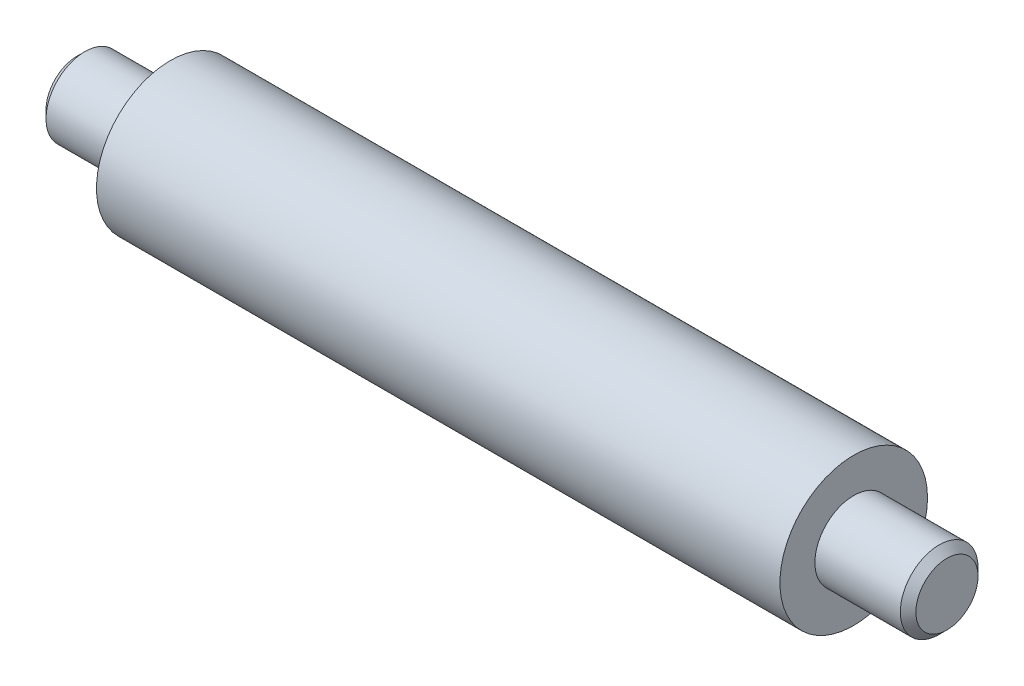
from build123d import *

# Parameters (mm, degrees)
SKETCH1_R           = 47.5
BOSS_EXTRUDE1_DEPTH = 220
SKETCH2_R           = 25
BOSS_EXTRUDE2_DEPTH = 280
CHAMFER1_SIZE       = 5


with BuildPart() as part:
    # Sketch1 → Boss-Extrude1 (new body, symmetric)
    with BuildSketch(Plane(origin=(0, 0, 0), x_dir=(0, 0, -1), z_dir=(1, 0, 0))):
        Circle(SKETCH1_R)
    extrude(amount=BOSS_EXTRUDE1_DEPTH, both=True)

    # Sketch2 → Boss-Extrude2 (add, symmetric)
    with BuildSketch(Plane(origin=(0, 0, 0), x_dir=(0, 0, -1), z_dir=(1, 0, 0))):
        Circle(SKETCH2_R)
    extrude(amount=BOSS_EXTRUDE2_DEPTH, both=True)

    # Chamfer1
    chamfer1_edges = [part.edges().sort_by_distance(p)[0] for p in [
        (-280, 0, 25),
        (280, 0, 25),
    ]]
    chamfer(chamfer1_edges, length=CHAMFER1_SIZE)


solid = part.part
